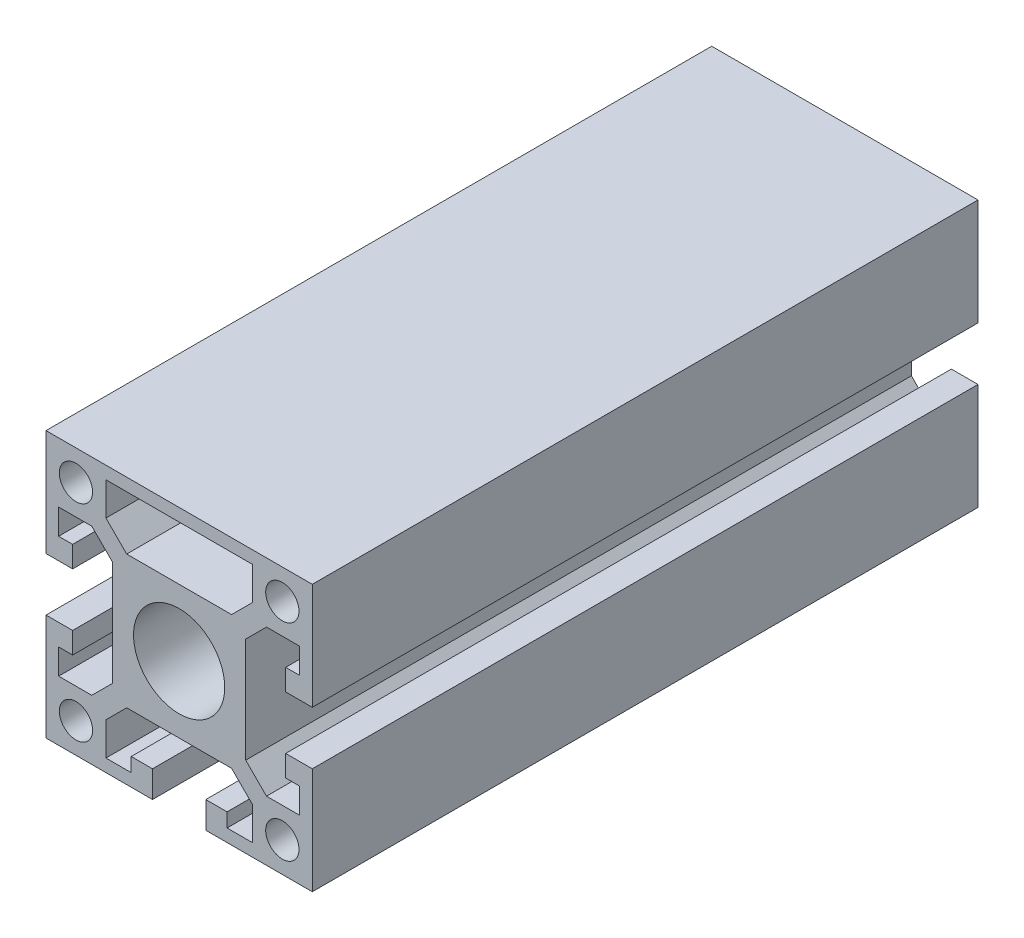
from build123d import *

# Parameters (mm, degrees)
SKETCH_C02_1_R   = 2.5
SKETCH_C02_1_R_2 = 6.85
EXTRUDE1_DEPTH   = 100


with BuildPart() as part:
    # Sketch C02-1 → Extrude1 (new body)
    with BuildSketch(Plane.XY):
        Polygon((-4, 20), (4, 20), (20, 20), (20, 4), (16, 4), (16, 7.2), (18.1, 7.2), (18.1, 11), (13.12132, 11), (10, 7.87868), (10, -7.87868), (13.12132, -11), (18.1, -11), (18.1, -7.2), (16, -7.2), (16, -4), (20, -4), (20, -20), (4, -20), (4, -16), (7.2, -16), (7.2, -18.1), (11, -18.1), (11, -13.12132), (7.87868, -10), (-7.87868, -10), (-11, -13.12132), (-11, -18.1), (-7.2, -18.1), (-7.2, -16), (-4, -16), (-4, -20), (-20, -20), (-20, -4), (-16, -4), (-16, -7.2), (-18.1, -7.2), (-18.1, -11), (-13.12132, -11), (-10, -7.87868), (-10, 7.87868), (-13.12132, 11), (-18.1, 11), (-18.1, 7.2), (-16, 7.2), (-16, 4), (-20, 4), (-20, 20), align=None)
        with Locations((-15.5, -15.5)):
            Circle(SKETCH_C02_1_R, mode=Mode.SUBTRACT)
        with Locations((-15.5, 15.5)):
            Circle(SKETCH_C02_1_R, mode=Mode.SUBTRACT)
        with Locations((15.5, -15.5)):
            Circle(SKETCH_C02_1_R, mode=Mode.SUBTRACT)
        with Locations((15.5, 15.5)):
            Circle(SKETCH_C02_1_R, mode=Mode.SUBTRACT)
        Circle(SKETCH_C02_1_R_2, mode=Mode.SUBTRACT)
        Polygon((-4, 18.1), (4, 18.1), (11, 18.1), (11, 13.12132), (7.87868, 10), (-7.87868, 10), (-11, 13.12132), (-11, 18.1), align=None, mode=Mode.SUBTRACT)
    extrude(amount=-EXTRUDE1_DEPTH)


solid = part.part
